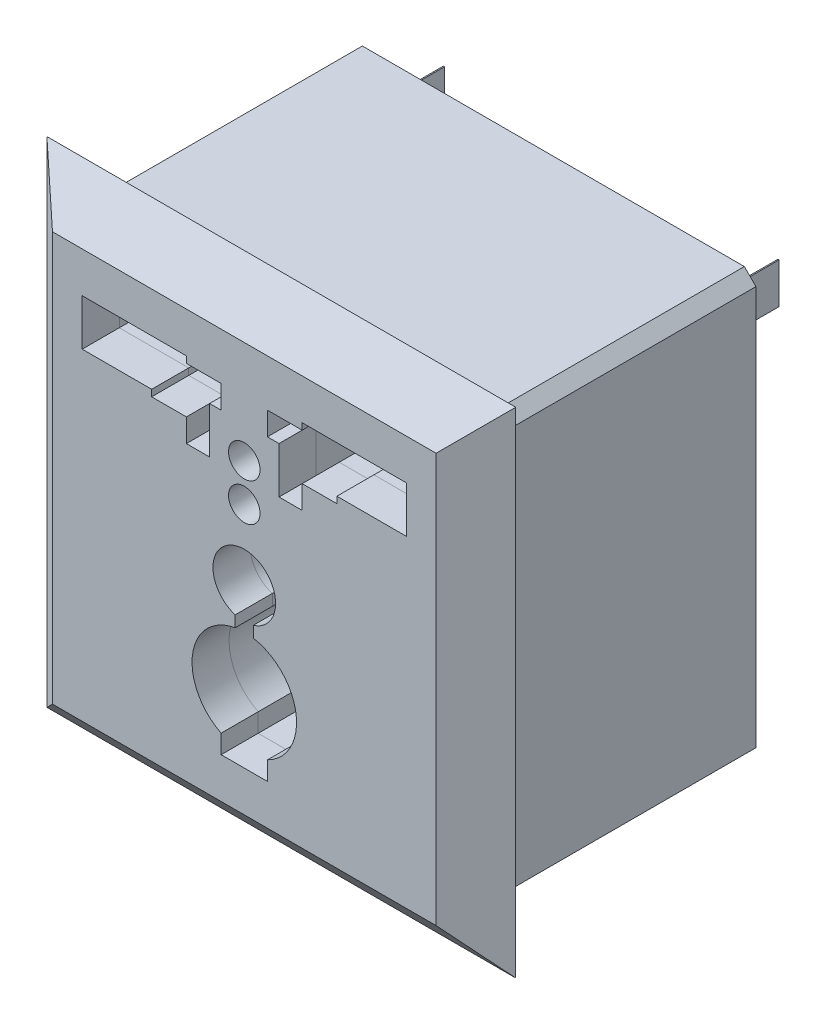
from build123d import *

# Parameters (mm, degrees)
SKETCH1_W           = 40.5
SKETCH1_H           = 42.7
BOSS_EXTRUDE1_DEPTH = 3.2
BOSS_EXTRUDE1_TAPER = 49
SKETCH6_W           = 35
SKETCH6_H           = 36.5
BOSS_EXTRUDE2_DEPTH = 23.5
CUT_EXTRUDE9_DEPTH  = 23.5
SKETCH13_W          = 0.1
SKETCH13_H          = 3.5
SKETCH13_W_2        = 3.5
SKETCH13_H_2        = 0.1
BOSS_EXTRUDE3_DEPTH = 5
SKETCH9_W           = 3
SKETCH9_H           = 0.564389357
SKETCH9_R           = 1.359977184
SKETCH9_H_2         = 1.44
SKETCH9_H_3         = 0.56
SKETCH9_H_4         = 1.435610643
CUT_EXTRUDE12_DEPTH = 15


with BuildPart() as part:
    # Sketch1 → Boss-Extrude1 (new body)
    with BuildSketch(Plane.XY):
        Rectangle(SKETCH1_W, SKETCH1_H)
    extrude(amount=BOSS_EXTRUDE1_DEPTH, taper=BOSS_EXTRUDE1_TAPER)


with BuildPart() as body_2:
    # Sketch6 → Boss-Extrude2 (new body)
    with BuildSketch(Plane(origin=(0, 0, 0), x_dir=(-1, 0, 0), z_dir=(0, 0, -1))):
        Rectangle(SKETCH6_W, SKETCH6_H)
    extrude(amount=BOSS_EXTRUDE2_DEPTH)

    # Sketch7 → Cut-Extrude9 (cut)
    with BuildSketch(Plane(origin=(0, 0, -23.5), x_dir=(-1, 0, 0), z_dir=(0, 0, -1))):
        Polygon((-17.5, 18.25), (-16.5, 18.25), (-17.5, 17.25), align=None)
        Polygon((17.5, 18.25), (17.5, 17.25), (16.5, 18.25), align=None)
        Polygon((17.5, -18.25), (17.5, -17.25), (16.5, -18.25), align=None)
        Polygon((-17.5, -18.25), (-16.5, -18.25), (-17.5, -17.25), align=None)
    extrude(amount=-CUT_EXTRUDE9_DEPTH, mode=Mode.SUBTRACT)

    # Sketch13 → Boss-Extrude3 (add)
    with BuildSketch(Plane(origin=(0, 0, -23.5), x_dir=(-1, 0, 0), z_dir=(0, 0, -1))):
        with Locations((-14.45, 13.5)):
            Rectangle(SKETCH13_W, SKETCH13_H)
        with Locations((14.45, 13.5)):
            Rectangle(SKETCH13_W, SKETCH13_H)
        with Locations((0, -15.2)):
            Rectangle(SKETCH13_W_2, SKETCH13_H_2)
    extrude(amount=BOSS_EXTRUDE3_DEPTH)


with BuildPart() as cut_extrude12_tool:
    # Sketch9 → Cut-Extrude12 (new body)
    with BuildSketch(Plane.XY.offset(3.2)):
        Polygon((-8, 11.60443174), (-5, 11.60443174), (-5, 13.60443174), (-5, 14.168821097), (-14, 14.168821097), (-14, 10.168821097), (-8, 10.168821097), align=None)
        with Locations((-6.5, 9.886626419)):
            Rectangle(SKETCH9_W, SKETCH9_H)
        Polygon((-5, 7.60443174), (-3, 7.60443174), (-3, 11.60443174), (-5, 11.60443174), (-5, 10.168821097), (-5, 9.60443174), align=None)
        Polygon((-5, 11.60443174), (-3, 11.60443174), (-2, 11.60443174), (-2, 13.60443174), (-5, 13.60443174), align=None)
        with Locations((0, 8.822296788)):
            Circle(SKETCH9_R)
        with Locations((0, 5.554779459)):
            Circle(SKETCH9_R)
        Polygon((5, 9.608821097), (5, 10.168821097), (5, 11.608821097), (3, 11.608821097), (3, 7.608821097), (5, 7.608821097), align=None)
        Polygon((3, 11.608821097), (5, 11.608821097), (5, 13.608821097), (2, 13.608821097), (2, 11.608821097), align=None)
        with Locations((6.5, 10.888821097)):
            Rectangle(SKETCH9_W, SKETCH9_H_2)
        with Locations((6.5, 9.888821097)):
            Rectangle(SKETCH9_W, SKETCH9_H_3)
        Polygon((8, 10.168821097), (14, 10.168821097), (14, 14.168821097), (5, 14.168821097), (5, 13.608821097), (5, 11.608821097), (8, 11.608821097), align=None)
        with Locations((-6.5, 10.886626419)):
            Rectangle(SKETCH9_W, SKETCH9_H_4)
        with BuildLine():
            ThreePointArc((2.707069994, -0.505416745), (-1.611804618, 1.667169446), (-0.781711039, -3.09557696))
            Line((-0.781711039, -3.09557696), (-0.781711039, -2.291060405))
            Line((-0.781711039, -2.291060405), (0.784068845, -2.291060405))
            Line((0.784068845, -2.291060405), (0.784068845, -3.09557696))
            ThreePointArc((0.784068845, -3.09557696), (2.173765095, -2.118400266), (2.707069994, -0.505416745))
        make_face()
        with BuildLine():
            Line((-0.781711039, -2.291060405), (-0.781711039, -3.09557696))
            ThreePointArc((-0.781711039, -3.09557696), (0.001178903, -3.211307837), (0.784068845, -3.09557696))
            Line((0.784068845, -3.09557696), (0.784068845, -2.291060405))
            Line((0.784068845, -2.291060405), (-0.781711039, -2.291060405))
        make_face()
        with BuildLine():
            Line((-0.781711039, -3.09557696), (-0.781711039, -4.060830569))
            ThreePointArc((-0.781711039, -4.060830569), (0.001178903, -3.992430641), (0.784068845, -4.060830569))
            Line((0.784068845, -4.060830569), (0.784068845, -3.09557696))
            ThreePointArc((0.784068845, -3.09557696), (0.001178903, -3.211307837), (-0.781711039, -3.09557696))
        make_face()
        with BuildLine():
            ThreePointArc((0.784068845, -4.060830569), (0.001178903, -3.992430641), (-0.781711039, -4.060830569))
            Line((-0.781711039, -4.060830569), (-0.781711039, -5.693800877))
            Line((-0.781711039, -5.693800877), (0.784068845, -5.693800877))
            Line((0.784068845, -5.693800877), (0.784068845, -4.060830569))
        make_face()
        with BuildLine():
            Line((2.001178903, -8.507020293), (2.001178903, -12.554429307))
            ThreePointArc((2.001178903, -12.554429307), (3.835934373, -10.889491743), (4.515768555, -8.507020293))
            ThreePointArc((4.515768555, -8.507020293), (3.459209163, -5.604685638), (0.784068845, -4.060830569))
            Line((0.784068845, -4.060830569), (0.784068845, -5.693800877))
            Line((0.784068845, -5.693800877), (-0.781711039, -5.693800877))
            Line((-0.781711039, -5.693800877), (-0.781711039, -4.060830569))
            ThreePointArc((-0.781711039, -4.060830569), (-4.467761015, -7.866633116), (-1.998821097, -12.554429307))
            Line((-1.998821097, -12.554429307), (-1.998821097, -8.507020293))
            Line((-1.998821097, -8.507020293), (2.001178903, -8.507020293))
        make_face()
        with BuildLine():
            ThreePointArc((-1.998821097, -12.554429307), (0.001178903, -13.021609945), (2.001178903, -12.554429307))
            Line((2.001178903, -12.554429307), (2.001178903, -8.507020293))
            Line((2.001178903, -8.507020293), (-1.998821097, -8.507020293))
            Line((-1.998821097, -8.507020293), (-1.998821097, -12.554429307))
        make_face()
        with BuildLine():
            Line((-1.998821097, -14.168821097), (2.001178903, -14.168821097))
            Line((2.001178903, -14.168821097), (2.001178903, -12.554429307))
            ThreePointArc((2.001178903, -12.554429307), (0.001178903, -13.021609945), (-1.998821097, -12.554429307))
            Line((-1.998821097, -12.554429307), (-1.998821097, -14.168821097))
        make_face()
    extrude(amount=-CUT_EXTRUDE12_DEPTH)


with BuildPart() as part_1:
    add(part.part)

    # Cut-Extrude12: cut by cut_extrude12_tool
    add(cut_extrude12_tool.part, mode=Mode.SUBTRACT)


with BuildPart() as body_2_1:
    add(body_2.part)

    # Cut-Extrude12: cut by cut_extrude12_tool
    add(cut_extrude12_tool.part, mode=Mode.SUBTRACT)


solid = Compound([part_1.part, body_2_1.part])
